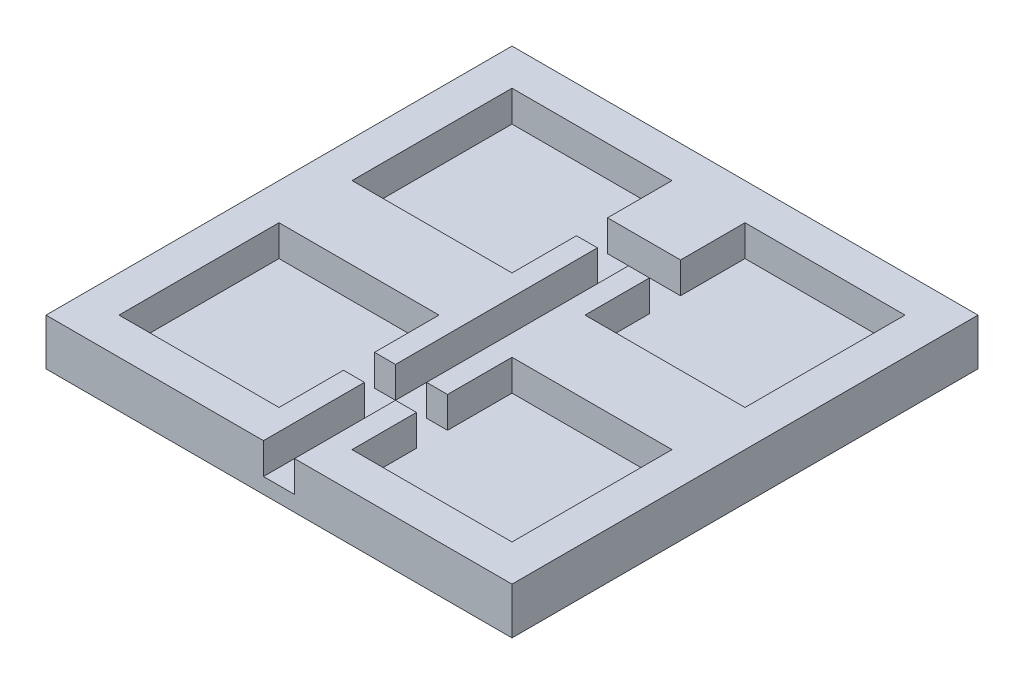
from build123d import *

# Parameters (mm, degrees)
BOTTOMSKETCH_W               = 30
BOTTOMSKETCH_H               = 30
BOTTOMEXTRUSION_DEPTH        = 3
HOLESKETCH_W                 = 10.3
HOLESKETCH_H                 = 10.3
HOLEEXTRUSION_DEPTH          = 2
LATERALWIRESKETCH_W          = 4.7
LATERALWIRESKETCH_H          = 2
LATERALWIREEXTRUSION_DEPTH   = 2
WIRERESEVOIRSKETCH_W         = 2
WIRERESEVOIRSKETCH_H         = 21.5
WIRERESERVOIREXTRUSION_DEPTH = 2


with BuildPart() as part:
    # bottomSketch → bottomExtrusion (new body)
    with BuildSketch(Plane(origin=(0, 0, 0), x_dir=(1, 0, 0), z_dir=(0, 1, 0))):
        Rectangle(BOTTOMSKETCH_W, BOTTOMSKETCH_H)
    extrude(amount=BOTTOMEXTRUSION_DEPTH)

    # holeSketch → holeExtrusion (cut)
    with BuildSketch(Plane(origin=(0, 3, 0), x_dir=(1, 0, 0), z_dir=(0, 1, 0))):
        with Locations((-7.5, 7.5)):
            Rectangle(HOLESKETCH_W, HOLESKETCH_H)
        with Locations((-7.5, -7.5)):
            Rectangle(HOLESKETCH_W, HOLESKETCH_H)
        with Locations((7.5, 7.5)):
            Rectangle(HOLESKETCH_W, HOLESKETCH_H)
        with Locations((7.5, -7.5)):
            Rectangle(HOLESKETCH_W, HOLESKETCH_H)
    extrude(amount=-HOLEEXTRUSION_DEPTH, mode=Mode.SUBTRACT)

    # lateralWireSketch → lateralWireExtrusion (cut)
    with BuildSketch(Plane(origin=(0, 3, 0), x_dir=(1, 0, 0), z_dir=(0, 1, 0))):
        with Locations((0, -7.5)):
            Rectangle(LATERALWIRESKETCH_W, LATERALWIRESKETCH_H)
        with Locations((0, 7.5)):
            Rectangle(LATERALWIRESKETCH_W, LATERALWIRESKETCH_H)
    extrude(amount=-LATERALWIREEXTRUSION_DEPTH, mode=Mode.SUBTRACT)

    # wireResevoirSketch → wireReservoirExtrusion (cut)
    with BuildSketch(Plane(origin=(0, 3, 0), x_dir=(1, 0, 0), z_dir=(0, 1, 0))):
        with Locations((0, -4.25)):
            Rectangle(WIRERESEVOIRSKETCH_W, WIRERESEVOIRSKETCH_H)
    extrude(amount=-WIRERESERVOIREXTRUSION_DEPTH, mode=Mode.SUBTRACT)


solid = part.part
